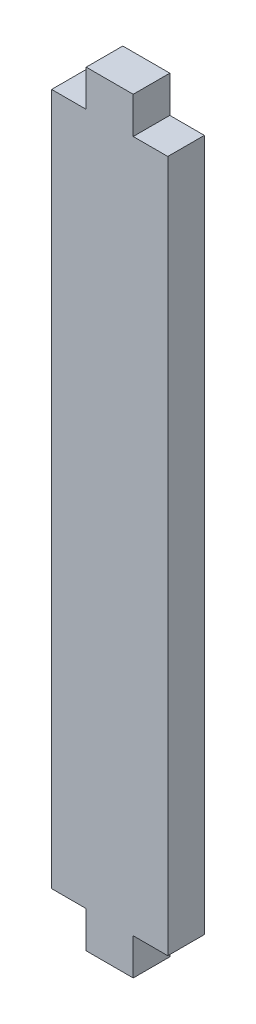
from build123d import *

# Parameters (mm, degrees)
SKETCH1_W           = 10
SKETCH1_H           = 60
SKETCH1_W_2         = 4
SKETCH1_H_2         = 3.175
BOSS_EXTRUDE1_DEPTH = 3.175
BOSS_EXTRUDE2_DEPTH = 3.175


with BuildPart() as part:
    # Sketch1 → Boss-Extrude1 (new body)
    with BuildSketch(Plane.XY):
        Rectangle(SKETCH1_W, SKETCH1_H)
        with Locations((0, 31.5875)):
            Rectangle(SKETCH1_W_2, SKETCH1_H_2)
        with Locations((0, -31.5875)):
            Rectangle(SKETCH1_W_2, SKETCH1_H_2)
    extrude(amount=BOSS_EXTRUDE1_DEPTH)

    # Sketch2 → Boss-Extrude2 (add)
    with BuildSketch(Plane.XY.offset(3.175)):
        Polygon((5.04064, -30.04064), (5.04064, 30.04064), (2.04064, 30.04064), (2.04064, 33.21564), (-2.04064, 33.21564), (-2.04064, 30.04064), (-5.04064, 30.04064), (-5.04064, -30.04064), (-2.04064, -30.04064), (-2.04064, -33.21564), (2.04064, -33.21564), (2.04064, -30.04064), align=None)
    extrude(amount=-BOSS_EXTRUDE2_DEPTH)


solid = part.part
